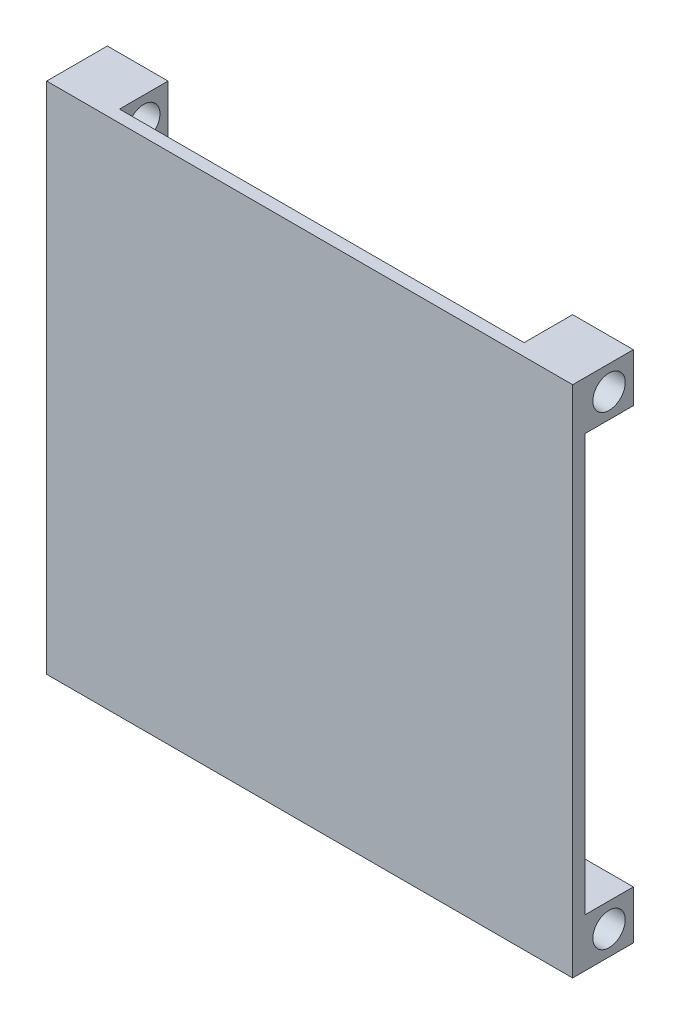
from build123d import *

# Parameters (mm, degrees)
ESQUISSE1_W             = 130
ESQUISSE1_H             = 127
BOSS_EXTRU_1_DEPTH      = 3
ESQUISSE2_W             = 12
ESQUISSE2_H             = 12
ESQUISSE2_R             = 4
BOSS_EXTRU_2_DEPTH      = 130
ESQUISSE3_W             = 100
ESQUISSE3_H             = 12
ENL_V_MAT_EXTRU_1_DEPTH = 160


with BuildPart() as part:
    # Esquisse1 → Boss.-Extru.1 (new body)
    with BuildSketch(Plane.XY):
        with Locations((-65, 63.5)):
            Rectangle(ESQUISSE1_W, ESQUISSE1_H)
    extrude(amount=BOSS_EXTRU_1_DEPTH)

    # Esquisse2 → Boss.-Extru.2 (add)
    with BuildSketch(Plane(origin=(0, 0, 0), x_dir=(0, 0, -1), z_dir=(1, 0, 0))):
        with Locations((6, 6)):
            Rectangle(ESQUISSE2_W, ESQUISSE2_H)
        with Locations((6, 6)):
            Circle(ESQUISSE2_R, mode=Mode.SUBTRACT)
        with Locations((6, 121)):
            Rectangle(ESQUISSE2_W, ESQUISSE2_H)
        with Locations((6, 121)):
            Circle(ESQUISSE2_R, mode=Mode.SUBTRACT)
    extrude(amount=-BOSS_EXTRU_2_DEPTH)

    # Esquisse3 → Enlèv. mat.-Extru.1 (cut)
    with BuildSketch(Plane(origin=(0, 127, 0), x_dir=(1, 0, 0), z_dir=(0, 1, 0))):
        with Locations((-65, 6)):
            Rectangle(ESQUISSE3_W, ESQUISSE3_H)
    extrude(amount=-ENL_V_MAT_EXTRU_1_DEPTH, mode=Mode.SUBTRACT)


solid = part.part
